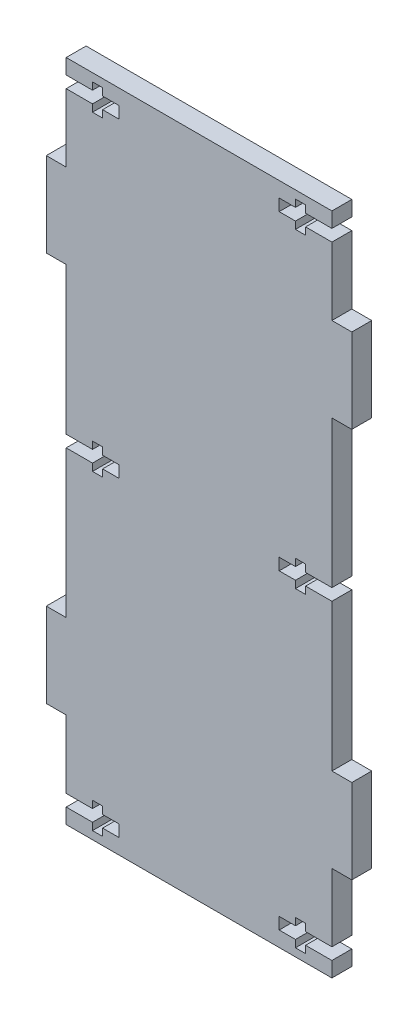
from build123d import *

# Parameters (mm, degrees)
SKETCH1_W           = 80.01
SKETCH1_H           = 200.025
BOSS_EXTRUDE1_DEPTH = 5.9944
SKETCH2_W           = 5.9944
SKETCH2_H           = 25.4
BOSS_EXTRUDE2_DEPTH = 5.9944
CUT_EXTRUDE1_DEPTH  = 6.9944


with BuildPart() as part:
    # Sketch1 → Boss-Extrude1 (new body)
    with BuildSketch(Plane.XY):
        with Locations((40.005, 100.0125)):
            Rectangle(SKETCH1_W, SKETCH1_H)
    extrude(amount=-BOSS_EXTRUDE1_DEPTH)

    # Sketch2 → Boss-Extrude2 (add)
    with BuildSketch(Plane.XY):
        with Locations((83.0072, 158.75)):
            Rectangle(SKETCH2_W, SKETCH2_H)
        with Locations((-2.9972, 158.75)):
            Rectangle(SKETCH2_W, SKETCH2_H)
        with Locations((-2.9972, 41.275)):
            Rectangle(SKETCH2_W, SKETCH2_H)
        with Locations((83.0072, 41.275)):
            Rectangle(SKETCH2_W, SKETCH2_H)
    extrude(amount=-BOSS_EXTRUDE2_DEPTH)

    # Sketch3 → Cut-Extrude1 (cut, through all)
    with BuildSketch(Plane.XY):
        Polygon((80.01, 195.453), (72.0852, 195.453), (72.0852, 197.6374), (69.0372, 197.6374), (69.0372, 195.453), (64.135, 195.453), (64.135, 191.897), (69.0372, 191.897), (69.0372, 189.7126), (72.0852, 189.7126), (72.0852, 191.897), (80.01, 191.897), align=None)
        Polygon((69.0372, 8.128), (64.135, 8.128), (64.135, 4.572), (69.0372, 4.572), (69.0372, 2.3876), (72.0852, 2.3876), (72.0852, 4.572), (80.01, 4.572), (80.01, 8.128), (72.0852, 8.128), (72.0852, 10.3124), (69.0372, 10.3124), align=None)
        Polygon((69.0372, 96.0501), (69.0372, 98.2345), (64.135, 98.2345), (64.135, 101.7905), (69.0372, 101.7905), (69.0372, 103.9749), (72.0852, 103.9749), (72.0852, 101.7905), (80.01, 101.7905), (80.01, 98.2345), (72.0852, 98.2345), (72.0852, 96.0501), align=None)
        Polygon((10.9728, 10.3124), (10.9728, 8.128), (15.875, 8.128), (15.875, 4.572), (10.9728, 4.572), (10.9728, 2.3876), (7.9248, 2.3876), (7.9248, 4.572), (0, 4.572), (0, 8.128), (7.9248, 8.128), (7.9248, 10.3124), align=None)
        Polygon((7.9248, 96.0501), (10.9728, 96.0501), (10.9728, 98.2345), (15.875, 98.2345), (15.875, 101.7905), (10.9728, 101.7905), (10.9728, 103.9749), (7.9248, 103.9749), (7.9248, 101.7905), (0, 101.7905), (0, 98.2345), (7.9248, 98.2345), align=None)
        Polygon((0, 195.453), (7.9248, 195.453), (7.9248, 197.6374), (10.9728, 197.6374), (10.9728, 195.453), (15.875, 195.453), (15.875, 191.897), (10.9728, 191.897), (10.9728, 189.7126), (7.9248, 189.7126), (7.9248, 191.897), (0, 191.897), align=None)
    extrude(amount=-CUT_EXTRUDE1_DEPTH, mode=Mode.SUBTRACT)


solid = part.part
